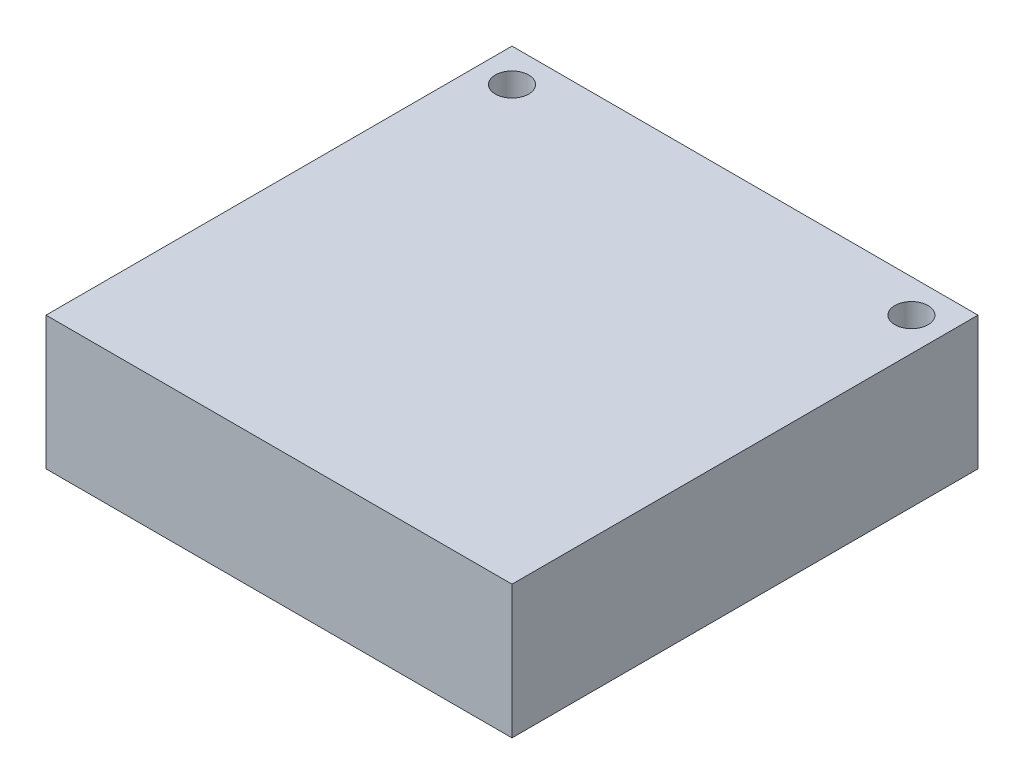
from build123d import *

# Parameters (mm, degrees)
SKETCH1_W           = 28
SKETCH1_H           = 28
BOSS_EXTRUDE1_DEPTH = 8
SKETCH2_R           = 1
CUT_EXTRUDE1_DEPTH  = 8


with BuildPart() as part:
    # Sketch1 → Boss-Extrude1 (new body)
    with BuildSketch(Plane(origin=(0, 0, 0), x_dir=(1, 0, 0), z_dir=(0, 1, 0))):
        with Locations((-14, -14)):
            Rectangle(SKETCH1_W, SKETCH1_H)
    extrude(amount=BOSS_EXTRUDE1_DEPTH)

    # Sketch2 → Cut-Extrude1 (cut)
    with BuildSketch(Plane(origin=(0, 8, 0), x_dir=(1, 0, 0), z_dir=(0, 1, 0))):
        with Locations((-26, -2)):
            Circle(SKETCH2_R)
        with Locations((-2, -2)):
            Circle(SKETCH2_R)
    extrude(amount=-CUT_EXTRUDE1_DEPTH, mode=Mode.SUBTRACT)


solid = part.part
